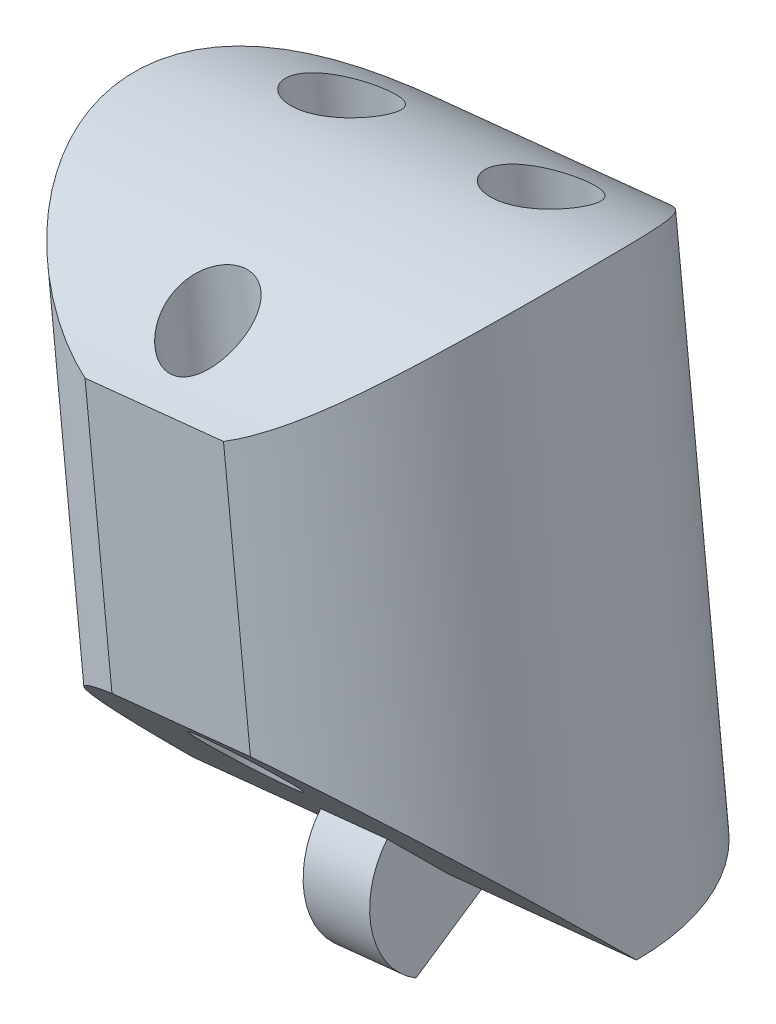
from build123d import *

# Parameters (mm, degrees)
SKETCH3_R               = 8
BOSS_EXTRUDE1_DEPTH     = 20.490526316
CUT_EXTRUDE1_DEPTH      = 11.102334007
CUT_EXTRUDE1_DEPTH_BACK = 11.102334007
CUT_EXTRUDE2_DEPTH      = 11.089230335
CUT_EXTRUDE2_DEPTH_BACK = 11.089230335
BOSS_EXTRUDE3_DEPTH     = 1.2
SKETCH8_R               = 1.6
SKETCH8_R_2             = 1.4
CUT_EXTRUDE3_DEPTH      = 24.833519451
CUT_EXTRUDE3_DEPTH_BACK = 2.513887999
CUT_EXTRUDE4_DEPTH      = 23.004414315


with BuildPart() as part:
    # Sketch3 → Boss-Extrude1 (new body)
    with BuildSketch(Plane(origin=(-12.082314344, 217.636022384, 0), x_dir=(-0.994665758, -0.103150523, 0), z_dir=(0.103150523, -0.994665758, 0))):
        Circle(SKETCH3_R)
    extrude(amount=BOSS_EXTRUDE1_DEPTH)

    # Sketch4 → Cut-Extrude1 (cut, two sides)
    with BuildSketch(Plane(origin=(10.375761543, 1.076004901, 0), x_dir=(0.103150523, -0.994665758, 0), z_dir=(-0.994665758, -0.103150523, 0))) as cut_extrude1_sk:
        with BuildLine():
            Line((-217.721396158, 8), (-213.721396158, 8))
            ThreePointArc((-213.721396158, 8), (-217.59367935, 0), (-213.721396158, -8))
            Line((-213.721396158, -8), (-217.721396158, -8))
            Line((-217.721396158, -8), (-217.721396158, 8))
        make_face()
    extrude(amount=CUT_EXTRUDE1_DEPTH, mode=Mode.SUBTRACT)
    extrude(cut_extrude1_sk.sketch, amount=-CUT_EXTRUDE1_DEPTH_BACK, mode=Mode.SUBTRACT)

    # Sketch5 → Cut-Extrude2 (cut, two sides)
    with BuildSketch(Plane(origin=(10.375761543, 1.076004901, 0), x_dir=(0.103150523, -0.994665758, 0), z_dir=(-0.994665758, -0.103150523, 0))) as cut_extrude2_sk:
        Polygon((-197.230869842, 0), (-205.230869842, 8), (-197.230869842, 8), align=None)
    extrude(amount=CUT_EXTRUDE2_DEPTH, mode=Mode.SUBTRACT)
    extrude(cut_extrude2_sk.sketch, amount=-CUT_EXTRUDE2_DEPTH_BACK, mode=Mode.SUBTRACT)

    # Sketch7 → Boss-Extrude3 (add, symmetric)
    with BuildSketch(Plane(origin=(10.375761543, 1.076004901, 0), x_dir=(0.103150523, -0.994665758, 0), z_dir=(-0.994665758, -0.103150523, 0))):
        with BuildLine():
            Line((-199.210768829, 1.979898987), (-197.230869842, 0))
            Line((-197.230869842, 0), (-197.230869842, -2.8))
            Line((-197.230869842, -2.8), (-194.805998711, 1.4))
            ThreePointArc((-194.805998711, 1.4), (-196.865396504, 2.776045612), (-199.210768829, 1.979898987))
        make_face()
    extrude(amount=BOSS_EXTRUDE3_DEPTH, both=True)

    # Sketch8 → Cut-Extrude3 (cut, two sides)
    with BuildSketch(Plane(origin=(-12.082314344, 217.636022384, 0), x_dir=(-0.994665758, -0.103150523, 0), z_dir=(0.103150523, -0.994665758, 0))) as cut_extrude3_sk:
        with Locations((-3.6, 3)):
            Circle(SKETCH8_R)
        with Locations((3.6, 3)):
            Circle(SKETCH8_R)
        with Locations((0, -5.5)):
            Circle(SKETCH8_R_2)
    extrude(amount=CUT_EXTRUDE3_DEPTH, mode=Mode.SUBTRACT)
    extrude(cut_extrude3_sk.sketch, amount=-CUT_EXTRUDE3_DEPTH_BACK, mode=Mode.SUBTRACT)

    # Sketch9 → Cut-Extrude4 (cut, through all)
    with BuildSketch(Plane(origin=(-20.344467381, 196.178792599, 0), x_dir=(0.994665758, 0.103150523, 0), z_dir=(0.103150523, -0.994665758, 0))):
        with BuildLine():
            Line((7.933405986, -7.6), (12.929404385, -7.6))
            ThreePointArc((12.929404385, -7.6), (10.431405186, -8), (7.933405986, -7.6))
        make_face()
        with BuildLine():
            Line((7.933405986, 7.6), (12.929404385, 7.6))
            ThreePointArc((12.929404385, 7.6), (10.431405186, 8), (7.933405986, 7.6))
        make_face()
    extrude(amount=-CUT_EXTRUDE4_DEPTH, mode=Mode.SUBTRACT)


solid = part.part
